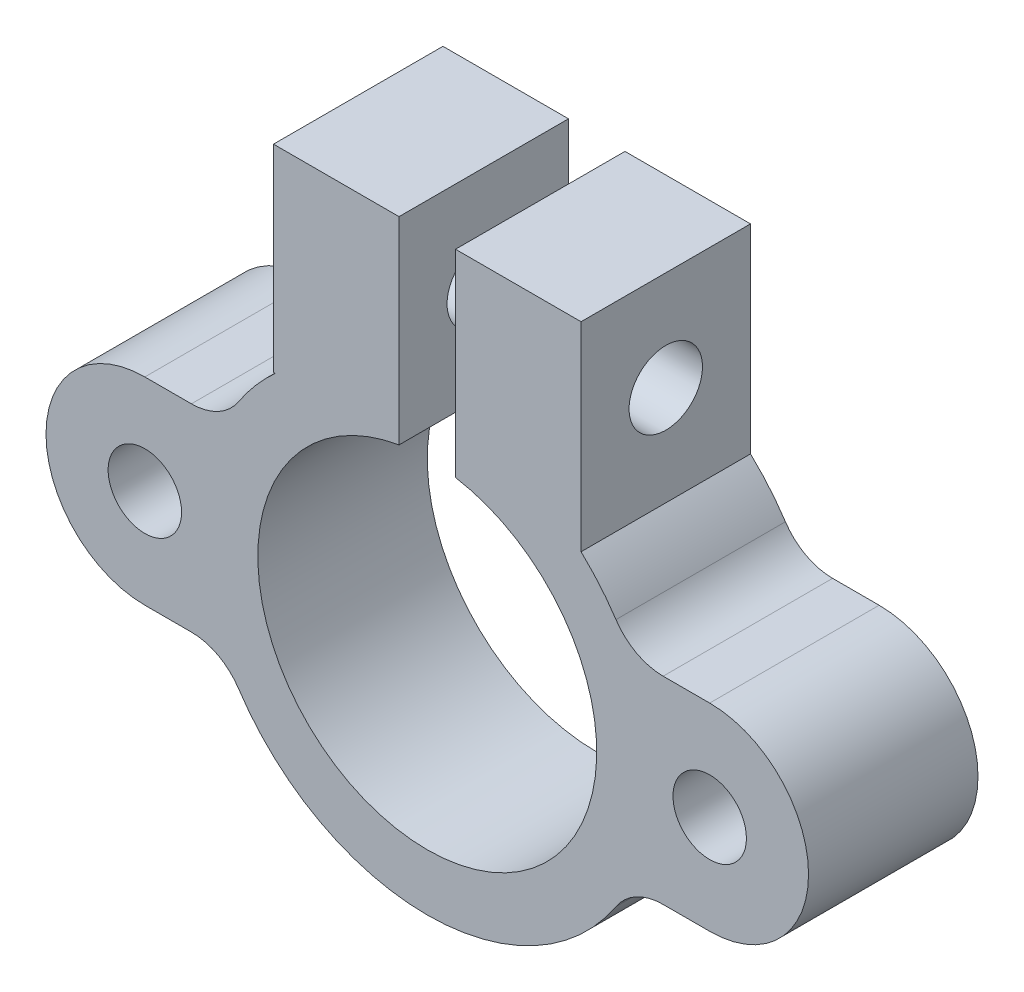
from build123d import *

# Parameters (mm, degrees)
SKETCH1_R           = 1.3
BOSS_EXTRUDE1_DEPTH = 6
SKETCH2_R           = 1.3
CUT_EXTRUDE1_DEPTH  = 11


with BuildPart() as part:
    # Sketch1 → Boss-Extrude1 (new body)
    with BuildSketch(Plane.XY):
        with BuildLine():
            Line((-10, 3.5), (-8.351646544, 3.5))
            ThreePointArc((-8.351646544, 3.5), (-7.402963246, 3.739318314), (-6.681317235, 4.4))
            ThreePointArc((-6.681317235, 4.4), (-6.080676089, 5.198593877), (-5.385164807, 5.916079783))
            Line((-5.385164807, 5.916079783), (-5.444775123, 5.916079783))
            Line((-5.444775123, 5.916079783), (-5.444775123, 12.916079783))
            Line((-5.444775123, 12.916079783), (-1, 12.916079783))
            Line((-1, 12.916079783), (-1, 5.916079783))
            ThreePointArc((-1, 5.916079783), (0, -6), (1, 5.916079783))
            Line((1, 5.916079783), (1, 12.916079783))
            Line((1, 12.916079783), (5.444775123, 12.916079783))
            Line((5.444775123, 12.916079783), (5.444775123, 5.861264698))
            ThreePointArc((5.444775123, 5.861264698), (6.106910233, 5.16775071), (6.681317235, 4.4))
            ThreePointArc((6.681317235, 4.4), (7.402963246, 3.739318314), (8.351646544, 3.5))
            Line((8.351646544, 3.5), (10, 3.5))
            ThreePointArc((10, 3.5), (13.5, 0), (10, -3.5))
            Line((10, -3.5), (8.351646544, -3.5))
            ThreePointArc((8.351646544, -3.5), (7.402963246, -3.739318314), (6.681317235, -4.4))
            ThreePointArc((6.681317235, -4.4), (0, -8), (-6.681317235, -4.4))
            ThreePointArc((-6.681317235, -4.4), (-7.402963246, -3.739318314), (-8.351646544, -3.5))
            Line((-8.351646544, -3.5), (-10, -3.5))
            ThreePointArc((-10, -3.5), (-13.5, 0), (-10, 3.5))
        make_face()
        with Locations((-10, 0)):
            Circle(SKETCH1_R, mode=Mode.SUBTRACT)
        with Locations((10, 0)):
            Circle(SKETCH1_R, mode=Mode.SUBTRACT)
    extrude(amount=BOSS_EXTRUDE1_DEPTH)

    # Sketch2 → Cut-Extrude1 (cut)
    with BuildSketch(Plane(origin=(5.444775123, 0, 0), x_dir=(0, 0, -1), z_dir=(1, 0, 0))):
        with Locations((-3, 9.388672241)):
            Circle(SKETCH2_R)
    extrude(amount=-CUT_EXTRUDE1_DEPTH, mode=Mode.SUBTRACT)


solid = part.part
